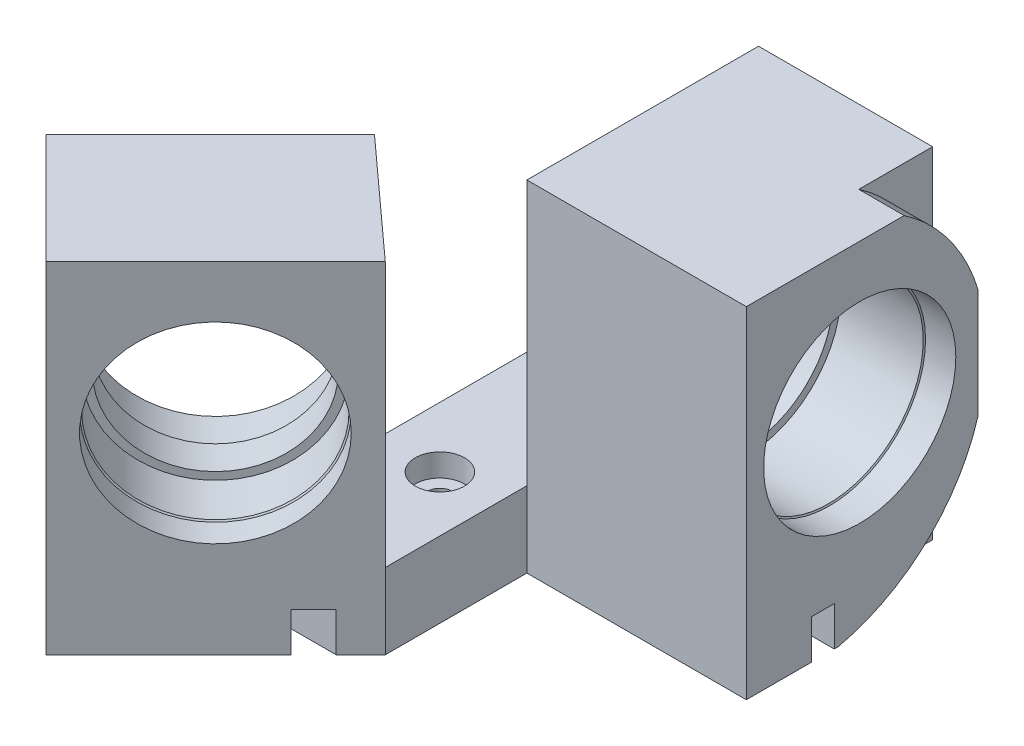
from build123d import *

# Parameters (mm, degrees)
BOSS_EXTRUDE1_DEPTH            = 45
SKETCH2_R                      = 12.5
CUT_EXTRUDE1_DEPTH             = 10
SKETCH3_R                      = 12.508139694
CUT_EXTRUDE2_DEPTH             = 15
CUT_EXTRUDE3_REACH             = 53.053
SKETCH4_R                      = 11.5
CUT_EXTRUDE4_REACH             = 53.015
SKETCH5_R                      = 11.5
SM1_TAPPED_HOLE1_D             = 25.4
SM1_TAPPED_HOLE1_DEPTH         = 4
SM1_TAPPED_HOLE1_TIP           = 7.630929862
SM1_TAPPED_HOLE2_D             = 25.4
SM1_TAPPED_HOLE2_DEPTH         = 3.5
SM1_TAPPED_HOLE2_TIP           = 7.630929862
CUT_EXTRUDE5_DEPTH             = 35
SM1_TAPPED_HOLE3_D             = 25.4
SM1_TAPPED_HOLE3_DEPTH         = 5.41
SM1_TAPPED_HOLE3_TIP           = 7.630929862
SM1_TAPPED_HOLE4_D             = 25.4
SM1_TAPPED_HOLE4_DEPTH         = 5.41
SM1_TAPPED_HOLE4_TIP           = 7.630929862
CBORE_FOR_M3_SHCS1_D           = 3.2
CBORE_FOR_M3_SHCS1_DEPTH       = 10
CBORE_FOR_M3_SHCS1_CBORE_D     = 6.5
CBORE_FOR_M3_SHCS1_CBORE_DEPTH = 3
CUT_EXTRUDE6_START             = -5.339235
CUT_EXTRUDE6_DEPTH             = 6
F_3_0MM_DOWEL_HOLE1_D          = 3
F_3_0MM_DOWEL_HOLE1_DEPTH      = 5.2
F_3_0MM_DOWEL_HOLE1_TIP        = 0.901290929
SKETCH21_W                     = 17.451379617
SKETCH21_H                     = 3
SKETCH21_W_2                   = 37.142162435
CUT_EXTRUDE7_DEPTH             = 5.2


with BuildPart() as part:
    # Sketch1 → Boss-Extrude1 (new body)
    with BuildSketch(Plane(origin=(0, 0, 0), x_dir=(1, 0, 0), z_dir=(0, 1, 0))):
        Polygon((5.319745859, 25.342678723), (-23.689372123, 25.342678723), (-23.689372123, 6.626389833), (-46.111095982, -15.795334027), (-60.695537468, -1.210892541), (-38.989042082, 20.495602845), (-38.989042082, 55.962281461), (5.319745859, 55.962281461), align=None)
    extrude(amount=BOSS_EXTRUDE1_DEPTH)

    # Sketch2 → Cut-Extrude1 (cut)
    with BuildSketch(Plane(origin=(-15.157880978, 0, -15.157880978), x_dir=(0.707106781, 0, -0.707106781), z_dir=(0.707106781, 0, 0.707106781))):
        with Locations((-27.941994438, 25.4)):
            Circle(SKETCH2_R)
    extrude(amount=-CUT_EXTRUDE1_DEPTH, mode=Mode.SUBTRACT)

    # Sketch3 → Cut-Extrude2 (cut)
    with BuildSketch(Plane(origin=(5.319745859, 0, 0), x_dir=(0, 0, -1), z_dir=(1, 0, 0))):
        with Locations((40.327918955, 25.4)):
            Circle(SKETCH3_R)
    extrude(amount=-CUT_EXTRUDE2_DEPTH, mode=Mode.SUBTRACT)

    # Sketch4 → Cut-Extrude3 (cut, up to next)
    with BuildSketch(Plane(origin=(-22.228948789, 0, -22.228948789), x_dir=(0.707106781, 0, -0.707106781), z_dir=(0.707106781, 0, 0.707106781)), mode=Mode.PRIVATE) as cut_extrude3_sk1:
        with Locations((-27.941994438, 25.4)):
            Circle(SKETCH4_R)
    cut_extrude3_tool1 = extrude(cut_extrude3_sk1.sketch, amount=-CUT_EXTRUDE3_REACH, mode=Mode.PRIVATE) & part.part
    add(cut_extrude3_tool1.solids().sort_by_distance((-41.986923, 25.4, -2.470975))[0], mode=Mode.SUBTRACT)

    # Sketch5 → Cut-Extrude4 (cut, up to next)
    with BuildSketch(Plane(origin=(-9.680254141, 0, 0), x_dir=(0, 0, -1), z_dir=(1, 0, 0)), mode=Mode.PRIVATE) as cut_extrude4_sk1:
        with Locations((40.327918955, 25.4)):
            Circle(SKETCH5_R)
    cut_extrude4_tool1 = extrude(cut_extrude4_sk1.sketch, amount=-CUT_EXTRUDE4_REACH, mode=Mode.PRIVATE) & part.part
    add(cut_extrude4_tool1.solids().sort_by_distance((-9.680254, 25.4, -40.327919))[0], mode=Mode.SUBTRACT)

    # SM1 Tapped Hole1
    with Locations(Plane(origin=(5.319745859, 0, 0), x_dir=(0, 0, -1), z_dir=(1, 0, 0))):
        with Locations((40.327918955, 25.4)):
            Hole(SM1_TAPPED_HOLE1_D / 2, depth=SM1_TAPPED_HOLE1_DEPTH)
            with Locations((0, 0, -(SM1_TAPPED_HOLE1_DEPTH + SM1_TAPPED_HOLE1_TIP / 2))):  # 118° drill point
                Cone(0, SM1_TAPPED_HOLE1_D / 2, SM1_TAPPED_HOLE1_TIP, mode=Mode.SUBTRACT)

    # SM1 Tapped Hole2
    with Locations(Plane(origin=(-15.157880978, 0, -15.157880978), x_dir=(0.707106781, 0, -0.707106781), z_dir=(0.707106781, 0, 0.707106781))):
        with Locations((-27.941994438, 25.4)):
            Hole(SM1_TAPPED_HOLE2_D / 2, depth=SM1_TAPPED_HOLE2_DEPTH)
            with Locations((0, 0, -(SM1_TAPPED_HOLE2_DEPTH + SM1_TAPPED_HOLE2_TIP / 2))):  # 118° drill point
                Cone(0, SM1_TAPPED_HOLE2_D / 2, SM1_TAPPED_HOLE2_TIP, mode=Mode.SUBTRACT)

    # Sketch11 → Cut-Extrude5 (cut)
    with BuildSketch(Plane(origin=(0, 45, 0), x_dir=(1, 0, 0), z_dir=(0, 1, 0))):
        Polygon((-23.689372123, 6.626389833), (-38.989042082, 20.495602845), (-38.989042082, 55.962281461), (-23.689372123, 55.962281461), align=None)
    extrude(amount=-CUT_EXTRUDE5_DEPTH, mode=Mode.SUBTRACT)

    # SM1 Tapped Hole3
    with Locations(Plane.ZY.offset(23.689372123)):
        with Locations((-40.327918955, 25.4)):
            Hole(SM1_TAPPED_HOLE3_D / 2, depth=SM1_TAPPED_HOLE3_DEPTH)
            with Locations((0, 0, -(SM1_TAPPED_HOLE3_DEPTH + SM1_TAPPED_HOLE3_TIP / 2))):  # 118° drill point
                Cone(0, SM1_TAPPED_HOLE3_D / 2, SM1_TAPPED_HOLE3_TIP, mode=Mode.SUBTRACT)

    # SM1 Tapped Hole4
    with Locations(Plane(origin=(-29.742322464, 0, -29.742322464), x_dir=(-0.707106781, 0, 0.707106781), z_dir=(-0.707106781, 0, -0.707106781))):
        with Locations((27.941994438, 25.4)):
            Hole(SM1_TAPPED_HOLE4_D / 2, depth=SM1_TAPPED_HOLE4_DEPTH)
            with Locations((0, 0, -(SM1_TAPPED_HOLE4_DEPTH + SM1_TAPPED_HOLE4_TIP / 2))):  # 118° drill point
                Cone(0, SM1_TAPPED_HOLE4_D / 2, SM1_TAPPED_HOLE4_TIP, mode=Mode.SUBTRACT)

    # CBORE for M3 SHCS1
    with Locations(Plane(origin=(0, 10, 0), x_dir=(1, 0, 0), z_dir=(0, 1, 0))):
        with Locations((-31.01569247, 48.433741468), (-31.01569247, 21.171407243)):
            CounterBoreHole(CBORE_FOR_M3_SHCS1_D / 2, CBORE_FOR_M3_SHCS1_CBORE_D / 2, CBORE_FOR_M3_SHCS1_CBORE_DEPTH, depth=CBORE_FOR_M3_SHCS1_DEPTH)

    # Sketch18 → Cut-Extrude6 (cut)
    with BuildSketch(Plane.ZY.offset(0.01948891).offset(CUT_EXTRUDE6_START)):
        with BuildLine():
            Line((-46.204849494, 45), (-56.766756342, 45))
            Line((-56.766756342, 45), (-56.766756342, 28.086826547))
            ThreePointArc((-56.766756342, 28.086826547), (-53.24503426, 37.642014764), (-46.204849494, 45))
        make_face()
        with BuildLine():
            Line((-56.619620621, 19.834105942), (-56.619620621, 0))
            Line((-56.619620621, 0), (-37.484367562, 0))
            ThreePointArc((-37.484367562, 0), (-50.031901767, 7.042142066), (-56.619620621, 19.834105942))
        make_face()
    extrude(amount=CUT_EXTRUDE6_DEPTH, mode=Mode.SUBTRACT)

    # Ø3.0mm Dowel Hole1
    with Locations(Plane(origin=(0, 0, 0), x_dir=(-1, 0, 0), z_dir=(0, -1, 0))):
        with Locations((42.575562076, 1.882335503), (30.989042082, 35.462281461)):
            Hole(F_3_0MM_DOWEL_HOLE1_D / 2, depth=F_3_0MM_DOWEL_HOLE1_DEPTH)
            with Locations((0, 0, -(F_3_0MM_DOWEL_HOLE1_DEPTH + F_3_0MM_DOWEL_HOLE1_TIP / 2))):  # 118° drill point
                Cone(0, F_3_0MM_DOWEL_HOLE1_D / 2, F_3_0MM_DOWEL_HOLE1_TIP, mode=Mode.SUBTRACT)

    # Sketch21 → Cut-Extrude7 (cut)
    with BuildSketch(Plane.XZ):
        with Locations((-33.849872268, -1.882335503)):
            Rectangle(SKETCH21_W, SKETCH21_H)
        with Locations((-12.417960864, -35.462281461)):
            Rectangle(SKETCH21_W_2, SKETCH21_H)
    extrude(amount=-CUT_EXTRUDE7_DEPTH, mode=Mode.SUBTRACT)


solid = part.part
